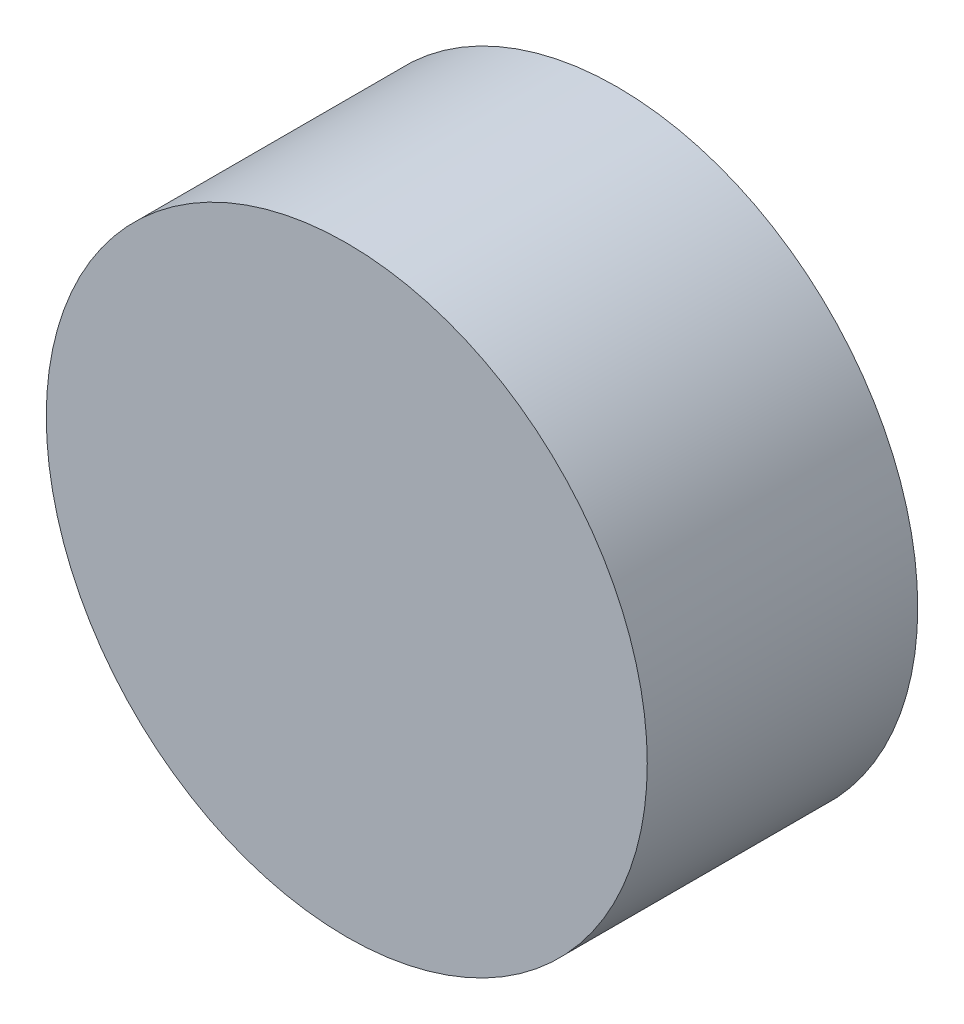
from build123d import *

# Parameters (mm, degrees)
SKETCH1_R           = 10
BOSS_EXTRUDE1_DEPTH = 9


with BuildPart() as part:
    # Sketch1 → Boss-Extrude1 (new body)
    with BuildSketch(Plane.XY):
        with Locations((0, -150.082)):
            Circle(SKETCH1_R)
    extrude(amount=BOSS_EXTRUDE1_DEPTH)


solid = part.part
